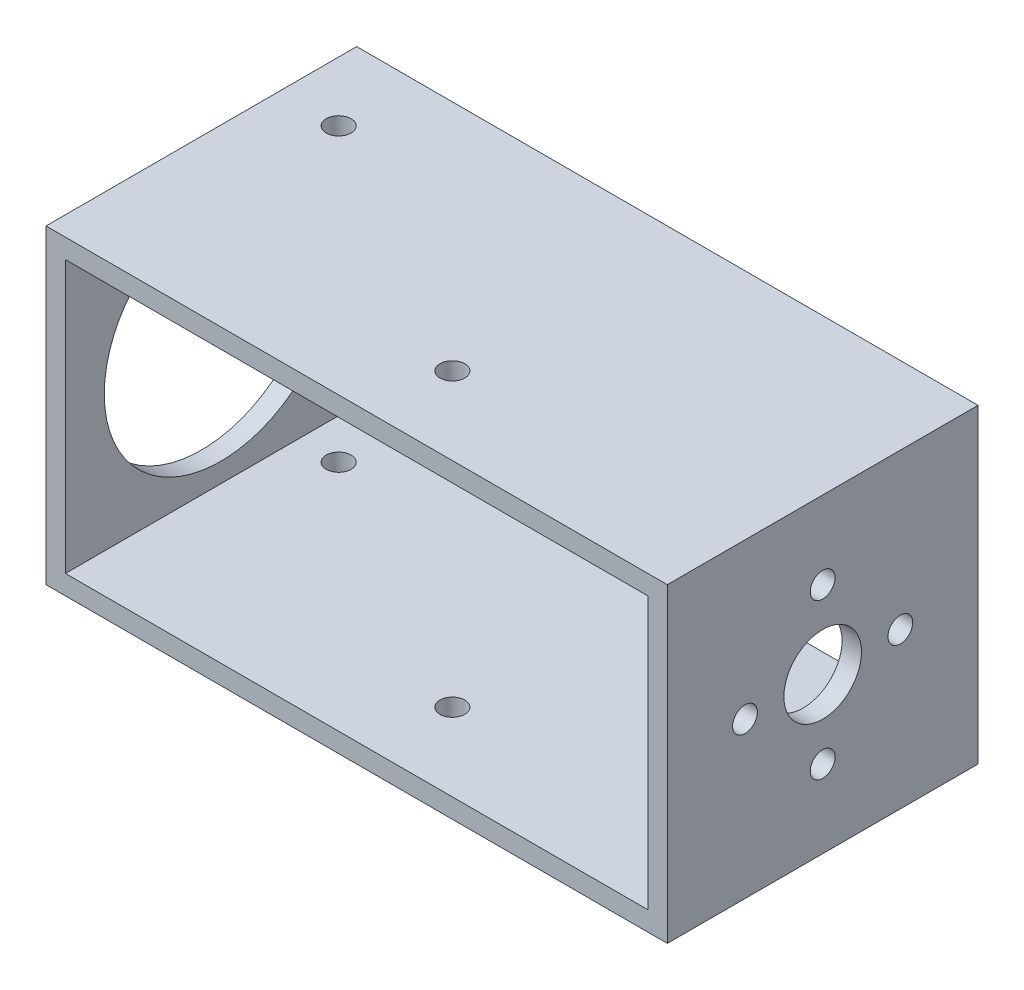
from build123d import *

# Parameters (mm, degrees)
SKETCH_1_W          = 80
SKETCH_1_H          = 40
SKETCH_1_W_2        = 75
SKETCH_1_H_2        = 35
EXTRUDE_1_DEPTH     = 20
CUT_EXTRUDE_1_REACH = 82
SKETCH_3_R          = 1.6
SKETCH_3_R_2        = 5
CUT_EXTRUDE_2_REACH = 82
SKETCH_4_R          = 15
SKETCH_5_R          = 1.6
CUT_EXTRUDE_3_DEPTH = 41


with BuildPart() as part:
    # ｽｹｯﾁ1 → ﾎﾞｽ - 押し出し1 (new body, symmetric)
    with BuildSketch(Plane.XY):
        Rectangle(SKETCH_1_W, SKETCH_1_H)
        Rectangle(SKETCH_1_W_2, SKETCH_1_H_2, mode=Mode.SUBTRACT)
    extrude(amount=EXTRUDE_1_DEPTH, both=True)

    # ｽｹｯﾁ3 → ｶｯﾄ - 押し出し1 (cut, up to next)
    with BuildSketch(Plane(origin=(40, 0, 0), x_dir=(0, 0, -1), z_dir=(1, 0, 0)), mode=Mode.PRIVATE) as cut_extrude_1_sk1:
        with Locations((0, 10)):
            Circle(SKETCH_3_R)
    cut_extrude_1_tool1 = extrude(cut_extrude_1_sk1.sketch, amount=-CUT_EXTRUDE_1_REACH, mode=Mode.PRIVATE) & part.part
    add(cut_extrude_1_tool1.solids().sort_by_distance((40, 10, 0))[0], mode=Mode.SUBTRACT)
    # ｽｹｯﾁ3 → ｶｯﾄ - 押し出し1 (cut, up to next)
    with BuildSketch(Plane(origin=(40, 0, 0), x_dir=(0, 0, -1), z_dir=(1, 0, 0)), mode=Mode.PRIVATE) as cut_extrude_1_sk2:
        with Locations((10, 0)):
            Circle(SKETCH_3_R)
    cut_extrude_1_tool2 = extrude(cut_extrude_1_sk2.sketch, amount=-CUT_EXTRUDE_1_REACH, mode=Mode.PRIVATE) & part.part
    add(cut_extrude_1_tool2.solids().sort_by_distance((40, 0, -10))[0], mode=Mode.SUBTRACT)
    # ｽｹｯﾁ3 → ｶｯﾄ - 押し出し1 (cut, up to next)
    with BuildSketch(Plane(origin=(40, 0, 0), x_dir=(0, 0, -1), z_dir=(1, 0, 0)), mode=Mode.PRIVATE) as cut_extrude_1_sk3:
        with Locations((0, -10)):
            Circle(SKETCH_3_R)
    cut_extrude_1_tool3 = extrude(cut_extrude_1_sk3.sketch, amount=-CUT_EXTRUDE_1_REACH, mode=Mode.PRIVATE) & part.part
    add(cut_extrude_1_tool3.solids().sort_by_distance((40, -10, 0))[0], mode=Mode.SUBTRACT)
    # ｽｹｯﾁ3 → ｶｯﾄ - 押し出し1 (cut, up to next)
    with BuildSketch(Plane(origin=(40, 0, 0), x_dir=(0, 0, -1), z_dir=(1, 0, 0)), mode=Mode.PRIVATE) as cut_extrude_1_sk4:
        with Locations((-10, 0)):
            Circle(SKETCH_3_R)
    cut_extrude_1_tool4 = extrude(cut_extrude_1_sk4.sketch, amount=-CUT_EXTRUDE_1_REACH, mode=Mode.PRIVATE) & part.part
    add(cut_extrude_1_tool4.solids().sort_by_distance((40, 0, 10))[0], mode=Mode.SUBTRACT)
    # ｽｹｯﾁ3 → ｶｯﾄ - 押し出し1 (cut, up to next)
    with BuildSketch(Plane(origin=(40, 0, 0), x_dir=(0, 0, -1), z_dir=(1, 0, 0)), mode=Mode.PRIVATE) as cut_extrude_1_sk5:
        Circle(SKETCH_3_R_2)
    cut_extrude_1_tool5 = extrude(cut_extrude_1_sk5.sketch, amount=-CUT_EXTRUDE_1_REACH, mode=Mode.PRIVATE) & part.part
    add(cut_extrude_1_tool5.solids().sort_by_distance((40, 0, 0))[0], mode=Mode.SUBTRACT)

    # ｽｹｯﾁ4 → ｶｯﾄ - 押し出し2 (cut, up to next)
    with BuildSketch(Plane.ZY.offset(40), mode=Mode.PRIVATE) as cut_extrude_2_sk1:
        Circle(SKETCH_4_R)
    cut_extrude_2_tool1 = extrude(cut_extrude_2_sk1.sketch, amount=-CUT_EXTRUDE_2_REACH, mode=Mode.PRIVATE) & part.part
    add(cut_extrude_2_tool1.solids().sort_by_distance((-40, 0, 0))[0], mode=Mode.SUBTRACT)

    # ｽｹｯﾁ5 → ｶｯﾄ - 押し出し3 (cut, through all)
    with BuildSketch(Plane.XZ.offset(20)):
        with Locations((-32.320508076, -10)):
            Circle(SKETCH_5_R)
        with Locations((2.320508076, 10)):
            Circle(SKETCH_5_R)
    extrude(amount=-CUT_EXTRUDE_3_DEPTH, mode=Mode.SUBTRACT)


solid = part.part
